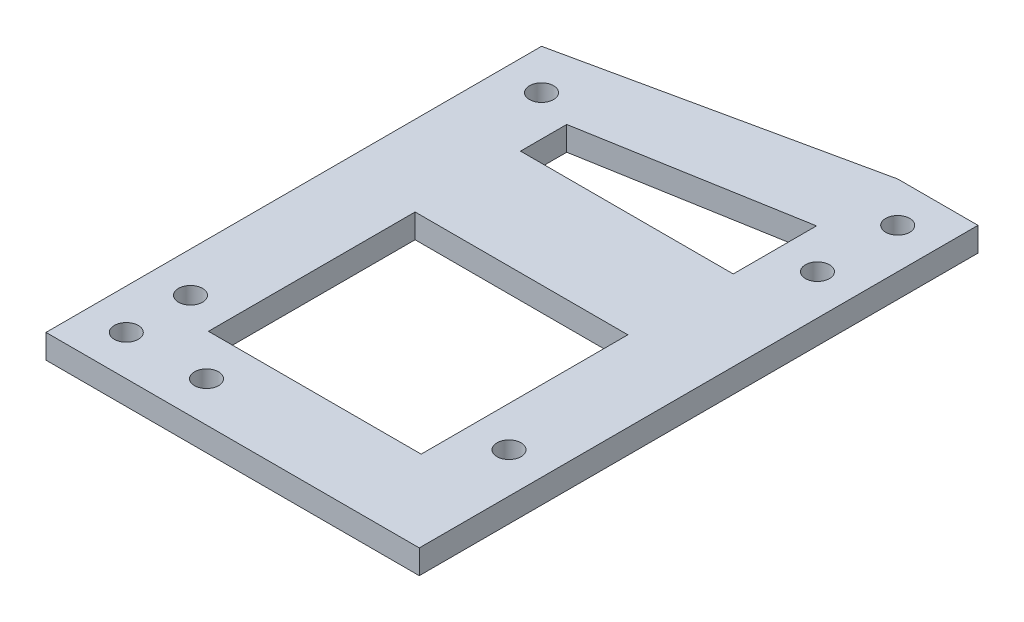
from build123d import *

# Parameters (mm, degrees)
SKETCH1_R           = 1.5
BOSS_EXTRUDE1_DEPTH = 3
SKETCH2_W           = 26.5
SKETCH2_H           = 13.12704922
BOSS_EXTRUDE2_DEPTH = 3
SKETCH3_R           = 1.5
CUT_EXTRUDE1_DEPTH  = 10
SKETCH4_R           = 1.5
CUT_EXTRUDE2_DEPTH  = 10


with BuildPart() as part:
    # Sketch1 → Boss-Extrude1 (new body)
    with BuildSketch(Plane(origin=(0, 0, 0), x_dir=(1, 0, 0), z_dir=(0, 1, 0))):
        Polygon((-5, -5), (41.5, -5), (41.5, 64.6), (31.5, 64.6), (-5, 56.73), align=None)
        Polygon((31.5, 54.48), (31.5, 5.234024539), (5, 5.234024539), (5, 56.73), align=None, mode=Mode.SUBTRACT)
        Circle(SKETCH1_R, mode=Mode.SUBTRACT)
        with Locations((0, 51.73)):
            Circle(SKETCH1_R, mode=Mode.SUBTRACT)
        with Locations((36.5, 59.6)):
            Circle(SKETCH1_R, mode=Mode.SUBTRACT)
        with Locations((36.5, 11.18)):
            Circle(SKETCH1_R, mode=Mode.SUBTRACT)
        with Locations((36.5, 49.6)):
            Circle(SKETCH1_R, mode=Mode.SUBTRACT)
    extrude(amount=BOSS_EXTRUDE1_DEPTH)

    # Sketch2 → Boss-Extrude2 (add)
    with BuildSketch(Plane(origin=(0, 3, 0), x_dir=(1, 0, 0), z_dir=(0, 1, 0))):
        with Locations((18.25, 37.545536879)):
            Rectangle(SKETCH2_W, SKETCH2_H)
        Polygon((5, 56.73), (5, 49.867078553), (31.5, 54.48), align=None)
    extrude(amount=-BOSS_EXTRUDE2_DEPTH)

    # Sketch3 → Cut-Extrude1 (cut)
    with BuildSketch(Plane(origin=(0, 3, 0), x_dir=(1, 0, 0), z_dir=(0, 1, 0))):
        with Locations((10, 0)):
            Circle(SKETCH3_R)
    extrude(amount=-CUT_EXTRUDE1_DEPTH, mode=Mode.SUBTRACT)

    # Sketch4 → Cut-Extrude2 (cut)
    with BuildSketch(Plane(origin=(0, 3, 0), x_dir=(1, 0, 0), z_dir=(0, 1, 0))):
        with Locations((0, 8)):
            Circle(SKETCH4_R)
    extrude(amount=-CUT_EXTRUDE2_DEPTH, mode=Mode.SUBTRACT)


solid = part.part
